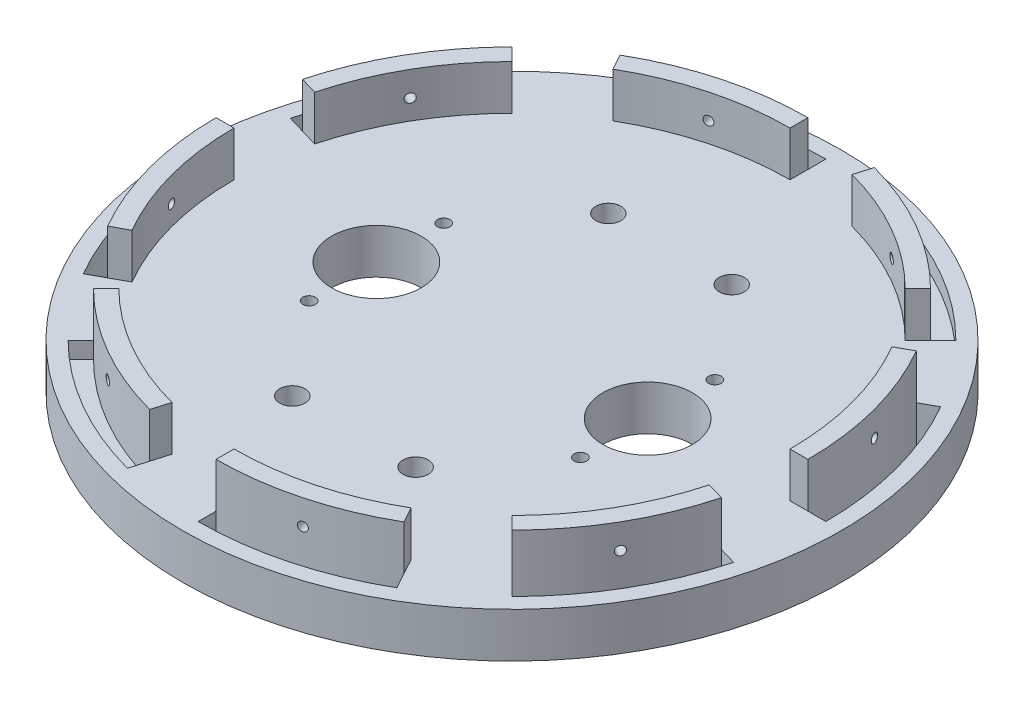
from build123d import *

# Parameters (mm, degrees)
SKETCH1_W                      = 127.635
SKETCH1_H                      = 127.635
MAIN_PLATE_DEPTH               = 12.7
SKETCH9_R                      = 93.345
BOSS_EXTRUDE1_DEPTH            = 12.7
SKETCH2_R                      = 3.556
U_BOLT_HOLE_DEPTH              = 12.7
U_BOLT_PATTERN_COUNT           = 2
U_BOLT_PATTERN_PITCH           = 34.925
U_BOLT_PATTERN_COUNT_DIR2      = 2
U_BOLT_PATTERN_PITCH_DIR2      = 89.535
SKETCH3_R                      = 1.778
RAPTOR_BOLT_HOLE_DEPTH         = 12.7
RAPTOR_BOLT_PATTERN_COUNT      = 2
RAPTOR_BOLT_PATTERN_PITCH      = 38.1
RAPTOR_BOLT_PATTERN_COUNT_DIR2 = 2
RAPTOR_BOLT_PATTERN_PITCH_DIR2 = 76.835
SKETCH4_R                      = 12.7
CO2_CYLINDER_HOLE_DEPTH        = 12.7
CO2_PATTERN_COUNT              = 2
CO2_PATTERN_PITCH              = 76.835
BOTTOM_SUPPORT_HOLE_DEPTH      = 13.7
BOTTOM_SUPPORT_GUIDE_DEPTH     = 12.7
SKETCH15_R                     = 1.27
BOTTOM_BOLT_HOLE_DEPTH         = 12.7
TOP_SUPPORT_HOLE_DEPTH         = 4.7625
TOP_SUPPORT_GUIDE_DEPTH        = 12.7
SKETCH21_R                     = 1.27
TOP_BOLT_HOLE_DEPTH            = 12.7
SUPPORT_PATTERN_COUNT          = 4


with BuildPart() as part:
    # Sketch1 → Main Plate (new body)
    with BuildSketch(Plane(origin=(0, 0, 0), x_dir=(1, 0, 0), z_dir=(0, 1, 0))):
        with Locations((63.8175, 63.8175)):
            Rectangle(SKETCH1_W, SKETCH1_H)
    extrude(amount=MAIN_PLATE_DEPTH)

    # Sketch9 → Boss-Extrude1 (add)
    with BuildSketch(Plane(origin=(0, 12.7, 0), x_dir=(1, 0, 0), z_dir=(0, 1, 0))):
        with Locations((63.8175, 63.8175)):
            Circle(SKETCH9_R)
    extrude(amount=-BOSS_EXTRUDE1_DEPTH)

    # Sketch2 → U-Bolt Hole (cut)
    with BuildSketch(Plane(origin=(0, 12.7, 0), x_dir=(1, 0, 0), z_dir=(0, 1, 0))):
        with Locations((46.355, 108.585)):
            Circle(SKETCH2_R)
    u_bolt_hole = extrude(amount=-U_BOLT_HOLE_DEPTH, mode=Mode.SUBTRACT)

    # U-Bolt Pattern: U-Bolt Hole 2 × 2
    with Locations(*[(i * U_BOLT_PATTERN_PITCH, 0, j * U_BOLT_PATTERN_PITCH_DIR2) for i in range(U_BOLT_PATTERN_COUNT) for j in range(U_BOLT_PATTERN_COUNT_DIR2) if (i, j) != (0, 0)]):
        add(u_bolt_hole, mode=Mode.SUBTRACT)

    # Sketch3 → Raptor Bolt Hole (cut)
    with BuildSketch(Plane(origin=(0, 12.7, 0), x_dir=(1, 0, 0), z_dir=(0, 1, 0))):
        with Locations((25.4, 44.7675)):
            Circle(SKETCH3_R)
    raptor_bolt_hole = extrude(amount=-RAPTOR_BOLT_HOLE_DEPTH, mode=Mode.SUBTRACT)

    # Raptor Bolt Pattern: Raptor Bolt Hole 2 × 2
    with Locations(*[(j * RAPTOR_BOLT_PATTERN_PITCH_DIR2, 0, -i * RAPTOR_BOLT_PATTERN_PITCH) for i in range(RAPTOR_BOLT_PATTERN_COUNT) for j in range(RAPTOR_BOLT_PATTERN_COUNT_DIR2) if (i, j) != (0, 0)]):
        add(raptor_bolt_hole, mode=Mode.SUBTRACT)

    # Sketch4 → Co2 Cylinder Hole (cut)
    with BuildSketch(Plane(origin=(0, 12.7, 0), x_dir=(1, 0, 0), z_dir=(0, 1, 0))):
        with Locations((25.4, 63.8175)):
            Circle(SKETCH4_R)
    co2_cylinder_hole = extrude(amount=-CO2_CYLINDER_HOLE_DEPTH, mode=Mode.SUBTRACT)

    # Co2 Pattern: Co2 Cylinder Hole ×2
    with Locations(*[(i * CO2_PATTERN_PITCH, 0, 0) for i in range(1, CO2_PATTERN_COUNT)]):
        add(co2_cylinder_hole, mode=Mode.SUBTRACT)

    # Sketch13 → Bottom support hole (cut, through all)
    with BuildSketch(Plane(origin=(0, 12.7, 0), x_dir=(1, 0, 0), z_dir=(0, 1, 0))):
        with BuildLine():
            Line((63.8175, 147.6375), (63.8175, 152.7175))
            ThreePointArc((63.8175, 152.7175), (40.840330772, 149.696832172), (19.42461027, 140.840102796))
            Line((19.42461027, 140.840102796), (21.860786069, 136.380758996))
            ThreePointArc((21.860786069, 136.380758996), (42.09723261, 144.774416842), (63.8175, 147.6375))
        make_face()
    bottom_support_hole = extrude(amount=-BOTTOM_SUPPORT_HOLE_DEPTH, mode=Mode.SUBTRACT)

    # Sketch14 → Bottom support guide (add)
    with BuildSketch(Plane(origin=(0, 12.7, 0), x_dir=(1, 0, 0), z_dir=(0, 1, 0))):
        with BuildLine():
            Line((63.8175, 147.6375), (63.8175, 142.5575))
            ThreePointArc((63.8175, 142.5575), (43.354144084, 139.851957088), (24.297048964, 131.921255769))
            Line((24.297048964, 131.921255769), (21.860786069, 136.380758996))
            ThreePointArc((21.860786069, 136.380758996), (42.09723261, 144.774416842), (63.8175, 147.6375))
        make_face()
    bottom_support_guide = extrude(amount=BOTTOM_SUPPORT_GUIDE_DEPTH)

    # Sketch15 → Bottom bolt hole (cut, symmetric)
    with BuildSketch(Plane(origin=(-32.665278477, 0, -121.751734722), x_dir=(0.965842482, 0, -0.25912989), z_dir=(0.25912989, 0, 0.965842482))):
        with Locations((78.177941748, 18.338063317)):
            Circle(SKETCH15_R)
    bottom_bolt_hole = extrude(amount=BOTTOM_BOLT_HOLE_DEPTH, both=True, mode=Mode.SUBTRACT)

    # Sketch17 → Top support hole (cut)
    with BuildSketch(Plane(origin=(-29.835322834, 12.7, 11.394633665), x_dir=(1, 0, 0), z_dir=(0, 1, 0))):
        with BuildLine():
            Line((34.383132435, 134.481824064), (30.791029986, 138.073926512))
            ThreePointArc((30.791029986, 138.073926512), (16.679652518, 119.690679634), (7.799104728, 98.284825042))
            Line((7.799104728, 98.284825042), (12.674973396, 96.854229229))
            ThreePointArc((12.674973396, 96.854229229), (21.049089591, 117.098770187), (34.383132435, 134.481824064))
        make_face()
    top_support_hole = extrude(amount=-TOP_SUPPORT_HOLE_DEPTH, mode=Mode.SUBTRACT)

    # Sketch19 → Top support guide (add)
    with BuildSketch(Plane(origin=(-29.835322834, 12.7, 11.394633665), x_dir=(1, 0, 0), z_dir=(0, 1, 0))):
        with BuildLine():
            Line((34.383132435, 134.481824064), (37.975234883, 130.889721615))
            ThreePointArc((37.975234883, 130.889721615), (25.418564889, 114.506836141), (17.551016382, 95.42358227))
            Line((17.551016382, 95.42358227), (12.674973396, 96.854229229))
            ThreePointArc((12.674973396, 96.854229229), (21.049089591, 117.098770187), (34.383132435, 134.481824064))
        make_face()
    top_support_guide = extrude(amount=TOP_SUPPORT_GUIDE_DEPTH)

    # Sketch21 → Top bolt hole (cut, symmetric)
    with BuildSketch(Plane(origin=(-49.866375142, 0, -28.76897147), x_dir=(0.499721266, 0, -0.866186271), z_dir=(0.866186271, 0, 0.499721266))):
        with Locations((87.172071643, 18.338063317)):
            Circle(SKETCH21_R)
    top_bolt_hole = extrude(amount=TOP_BOLT_HOLE_DEPTH, both=True, mode=Mode.SUBTRACT)

    # Support pattern: Bottom support hole, Bottom support guide, Bottom bolt hole, Top support hole, Top support guide, Top bolt hole ×4 about axis
    support_pattern_axis = Axis((63.8175, 0, -63.8175), (0, 1, 0))
    for i in range(1, SUPPORT_PATTERN_COUNT):
        add(bottom_support_hole.rotate(support_pattern_axis, i * 360 / SUPPORT_PATTERN_COUNT), mode=Mode.SUBTRACT)
        add(bottom_support_guide.rotate(support_pattern_axis, i * 360 / SUPPORT_PATTERN_COUNT))
        add(bottom_bolt_hole.rotate(support_pattern_axis, i * 360 / SUPPORT_PATTERN_COUNT), mode=Mode.SUBTRACT)
        add(top_support_hole.rotate(support_pattern_axis, i * 360 / SUPPORT_PATTERN_COUNT), mode=Mode.SUBTRACT)
        add(top_support_guide.rotate(support_pattern_axis, i * 360 / SUPPORT_PATTERN_COUNT))
        add(top_bolt_hole.rotate(support_pattern_axis, i * 360 / SUPPORT_PATTERN_COUNT), mode=Mode.SUBTRACT)


solid = part.part
